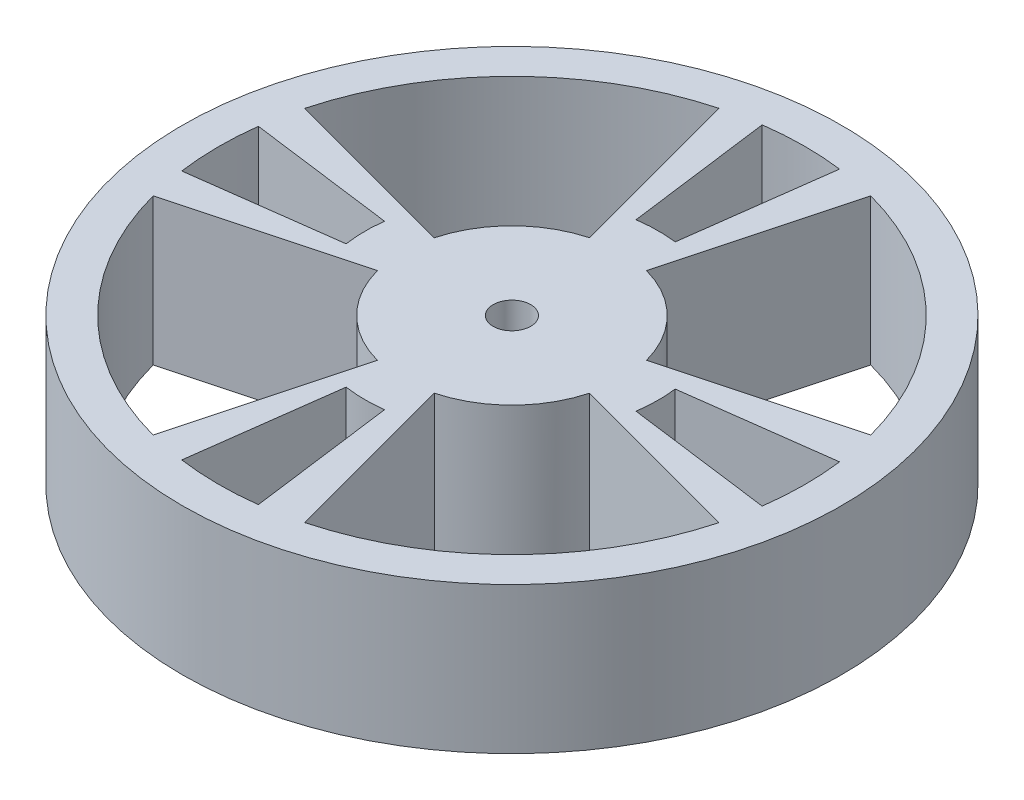
from build123d import *

# Parameters (mm, degrees)
SKETCH1_R           = 9.525
BOSS_EXTRUDE1_DEPTH = 2.54
SKETCH3_R           = 28.575
BOSS_EXTRUDE2_DEPTH = 12.7
CUT_EXTRUDE2_DEPTH  = 16.24
CUT_EXTRUDE3_DEPTH  = 8.466666667
SKETCH5_R           = 1.63195
CUT_EXTRUDE4_DEPTH  = 16.24


with BuildPart() as part:
    # Sketch1 → Boss-Extrude1 (new body)
    with BuildSketch(Plane(origin=(0, 0, 0), x_dir=(1, 0, 0), z_dir=(0, 1, 0))):
        Circle(SKETCH1_R)
    extrude(amount=BOSS_EXTRUDE1_DEPTH)

    # Sketch3 → Boss-Extrude2 (add)
    with BuildSketch(Plane(origin=(0, 2.54, 0), x_dir=(1, 0, 0), z_dir=(0, 1, 0))):
        Circle(SKETCH3_R)
        with BuildLine():
            Line((-2.465251405, 9.200443495), (-6.574003746, 24.534515988))
            ThreePointArc((-6.574003746, 24.534515988), (-17.960512242, 17.960512242), (-24.534515988, 6.574003746))
            Line((-24.534515988, 6.574003746), (-9.200443495, 2.465251405))
            ThreePointArc((-9.200443495, 2.465251405), (-6.735192091, 6.735192091), (-2.465251405, 9.200443495))
        make_face(mode=Mode.SUBTRACT)
        with BuildLine():
            Line((9.200443495, 2.465251405), (24.534515988, 6.574003746))
            ThreePointArc((24.534515988, 6.574003746), (17.960512242, 17.960512242), (6.574003746, 24.534515988))
            Line((6.574003746, 24.534515988), (2.465251405, 9.200443495))
            ThreePointArc((2.465251405, 9.200443495), (6.735192091, 6.735192091), (9.200443495, 2.465251405))
        make_face(mode=Mode.SUBTRACT)
        with BuildLine():
            Line((9.200443495, -2.465251405), (24.534515988, -6.574003746))
            ThreePointArc((24.534515988, -6.574003746), (17.960512242, -17.960512242), (6.574003746, -24.534515988))
            Line((6.574003746, -24.534515988), (2.465251405, -9.200443495))
            ThreePointArc((2.465251405, -9.200443495), (6.735192091, -6.735192091), (9.200443495, -2.465251405))
        make_face(mode=Mode.SUBTRACT)
        with BuildLine():
            Line((-9.200443495, -2.465251405), (-24.534515988, -6.574003746))
            ThreePointArc((-24.534515988, -6.574003746), (-17.960512242, -17.960512242), (-6.574003746, -24.534515988))
            Line((-6.574003746, -24.534515988), (-2.465251405, -9.200443495))
            ThreePointArc((-2.465251405, -9.200443495), (-6.735192091, -6.735192091), (-9.200443495, -2.465251405))
        make_face(mode=Mode.SUBTRACT)
    extrude(amount=BOSS_EXTRUDE2_DEPTH)

    # Sketch4 → Cut-Extrude2 (cut, through all)
    with BuildSketch(Plane(origin=(0, 15.24, 0), x_dir=(1, 0, 0), z_dir=(0, 1, 0))):
        with BuildLine():
            Line((12.604555768, 1.554082971), (25.196118384, 3.211793638))
            ThreePointArc((25.196118384, 3.211793638), (25.399675108, -0.128469484), (25.162340107, -3.466502611))
            Line((25.162340107, -3.466502611), (12.570536445, -1.80876021))
            ThreePointArc((12.570536445, -1.80876021), (12.699350202, -0.128469656), (12.604555768, 1.554082971))
        make_face()
        with BuildLine():
            Line((-12.604555768, 1.554082971), (-25.196118384, 3.211793638))
            ThreePointArc((-25.196118384, 3.211793638), (-25.399675108, -0.128469484), (-25.162340107, -3.466502611))
            Line((-25.162340107, -3.466502611), (-12.570536445, -1.80876021))
            ThreePointArc((-12.570536445, -1.80876021), (-12.699350202, -0.128469656), (-12.604555768, 1.554082971))
        make_face()
        with BuildLine():
            Line((1.554082971, 12.604555768), (3.211793638, 25.196118384))
            ThreePointArc((3.211793638, 25.196118384), (-0.128469484, 25.399675108), (-3.466502611, 25.162340107))
            Line((-3.466502611, 25.162340107), (-1.80876021, 12.570536445))
            ThreePointArc((-1.80876021, 12.570536445), (-0.128469656, 12.699350202), (1.554082971, 12.604555768))
        make_face()
        with BuildLine():
            Line((-1.80876021, -12.570536445), (-3.466502611, -25.162340107))
            ThreePointArc((-3.466502611, -25.162340107), (-0.128469484, -25.399675108), (3.211793638, -25.196118384))
            Line((3.211793638, -25.196118384), (1.554082971, -12.604555768))
            ThreePointArc((1.554082971, -12.604555768), (-0.128469656, -12.699350202), (-1.80876021, -12.570536445))
        make_face()
    extrude(amount=-CUT_EXTRUDE2_DEPTH, mode=Mode.SUBTRACT)

    # Sketch2 → Cut-Extrude3 (cut)
    with BuildSketch(Plane(origin=(0, 0, 0), x_dir=(1, 0, 0), z_dir=(0, 1, 0))):
        Polygon((-4.552853785, 1.885853785), (-1.885853785, 4.552853785), (0, 2.667), (1.885853785, 4.552853785), (4.552853785, 1.885853785), (2.667, 0), (4.552853785, -1.885853785), (1.885853785, -4.552853785), (0, -2.667), (-1.885853785, -4.552853785), (-4.552853785, -1.885853785), (-2.667, 0), align=None)
    extrude(amount=CUT_EXTRUDE3_DEPTH, mode=Mode.SUBTRACT)

    # Sketch5 → Cut-Extrude4 (cut, through all)
    with BuildSketch(Plane(origin=(0, 15.24, 0), x_dir=(1, 0, 0), z_dir=(0, 1, 0))):
        Circle(SKETCH5_R)
    extrude(amount=-CUT_EXTRUDE4_DEPTH, mode=Mode.SUBTRACT)


solid = part.part
